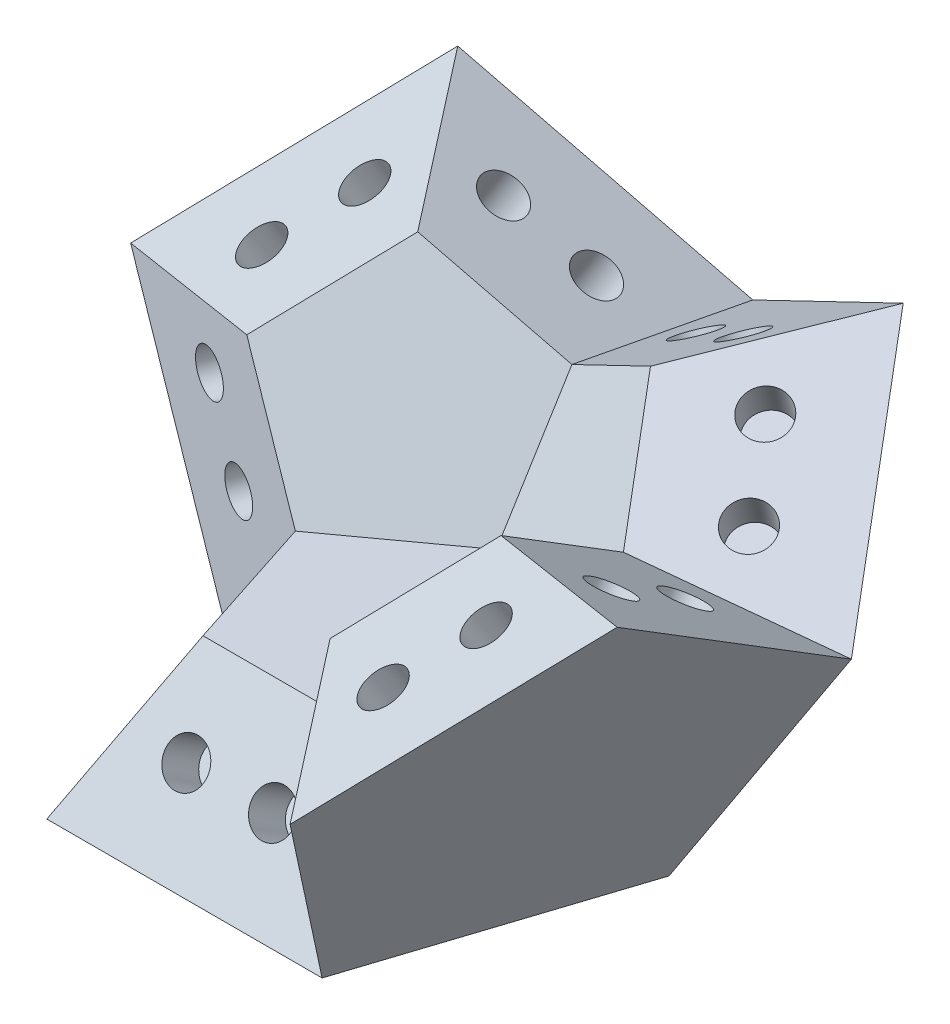
from build123d import *

# Parameters (mm, degrees)
BOSS_EXTRUDE1_DEPTH     = 6.752040791
BOSS_EXTRUDE1_TAPER     = 31.717474411
SKETCH3_R               = 1
CUT_EXTRUDE1_DEPTH      = 2
CIRPATTERN1_COUNT       = 5
MIRROR3_COPY_1_SKETCH_R = 1
MIRROR3_COPY_1_DEPTH    = 2
MIRROR3_COPY_2_SKETCH_R = 1
MIRROR3_COPY_2_DEPTH    = 2
MIRROR3_COPY_3_SKETCH_R = 1
MIRROR3_COPY_3_DEPTH    = 2
MIRROR3_COPY_4_SKETCH_R = 1
MIRROR3_COPY_4_DEPTH    = 2
MIRROR4_COPY_1_SKETCH_R = 1
MIRROR4_COPY_1_DEPTH    = 2
MIRROR4_COPY_2_SKETCH_R = 1
MIRROR4_COPY_2_DEPTH    = 2
MIRROR4_COPY_3_SKETCH_R = 1
MIRROR4_COPY_3_DEPTH    = 2
MIRROR4_COPY_4_SKETCH_R = 1
MIRROR4_COPY_4_DEPTH    = 2
MIRROR5_COPY_1_SKETCH_R = 1
MIRROR5_COPY_1_DEPTH    = 2
MIRROR5_COPY_2_SKETCH_R = 1
MIRROR5_COPY_2_DEPTH    = 2
MIRROR5_COPY_3_SKETCH_R = 1
MIRROR5_COPY_3_DEPTH    = 2
MIRROR5_COPY_4_SKETCH_R = 1
MIRROR5_COPY_4_DEPTH    = 2


with BuildPart() as part:
    # Sketch1 → Boss-Extrude1 (new body)
    with BuildSketch(Plane(origin=(0, 0, 0), x_dir=(1, 0, 0), z_dir=(0, 1, 0))):
        Polygon((0, 10.803265266), (-10.274515829, 3.338392562), (-6.35, -8.740025195), (6.35, -8.740025195), (10.274515829, 3.338392562), align=None)
    boss_extrude1 = extrude(amount=BOSS_EXTRUDE1_DEPTH, taper=BOSS_EXTRUDE1_TAPER)

    # Sketch3 → Cut-Extrude1 (cut)
    with BuildSketch(Plane(origin=(0, 3.908658092, 6.324341644), x_dir=(1, 0, 0), z_dir=(1.6266940928737823e-15, 0.5257311121191348, 0.8506508083520392))):
        with Locations((-2, -0.626153166)):
            Circle(SKETCH3_R)
        with Locations((2, -0.626153166)):
            Circle(SKETCH3_R)
    cut_extrude1 = extrude(amount=-CUT_EXTRUDE1_DEPTH, mode=Mode.SUBTRACT)

    # CirPattern1: Cut-Extrude1 ×5 about axis
    cirpattern1_axis = Axis((0, 14.848740719, 0), (0, -1, 0))
    for i in range(1, CIRPATTERN1_COUNT):
        add(cut_extrude1.rotate(cirpattern1_axis, i * 360 / CIRPATTERN1_COUNT), mode=Mode.SUBTRACT)

    # Mirror3: Boss-Extrude1, Cut-Extrude1 across plane
    add(boss_extrude1.mirror(Plane(origin=(10.274515829, 0, -3.338392562), x_dir=(0.4742680099309791, 0.49867489660708614, 0.7255296012224591), z_dir=(0.4999999999999987, 0.5257311121191346, -0.688190960235587))))
    add(cut_extrude1.mirror(Plane(origin=(10.274515829, 0, -3.338392562), x_dir=(0.4742680099309791, 0.49867489660708614, 0.7255296012224591), z_dir=(0.4999999999999987, 0.5257311121191346, -0.688190960235587))), mode=Mode.SUBTRACT)

    # Mirror3 copy 1 sketch → Mirror3 copy 1 (cut)
    with BuildSketch(Plane(origin=(3.717354749, 14.141657828, -11.440841512), x_dir=(0.8090169943749475, 0.5257311121191339, 0.26286555605956596), z_dir=(-0.5000000000000014, 0.8506508083520399, -0.16245984811644945))):
        with Locations((-2, 0.626153166)):
            Circle(MIRROR3_COPY_1_SKETCH_R)
        with Locations((2, 0.626153166)):
            Circle(MIRROR3_COPY_1_SKETCH_R)
    extrude(amount=-MIRROR3_COPY_1_DEPTH, mode=Mode.SUBTRACT)

    # Mirror3 copy 2 sketch → Mirror3 copy 2 (cut)
    with BuildSketch(Plane(origin=(0, 7.817316184, -10.232999736), x_dir=(-1.2043746199203667e-15, 0.8506508083520407, -0.5257311121191327), z_dir=(-1, 0, 0))):
        with Locations((-2, 0.626153166)):
            Circle(MIRROR3_COPY_2_SKETCH_R)
        with Locations((2, 0.626153166)):
            Circle(MIRROR3_COPY_2_SKETCH_R)
    extrude(amount=-MIRROR3_COPY_2_DEPTH, mode=Mode.SUBTRACT)

    # Mirror3 copy 3 sketch → Mirror3 copy 3 (cut)
    with BuildSketch(Plane(origin=(3.717354749, 3.908658092, -5.116499868), x_dir=(-0.8090169943749478, 0, -0.5877852522924727), z_dir=(-0.4999999999999993, -0.5257311121191345, 0.6881909602355869))):
        with Locations((-2, 0.626153166)):
            Circle(MIRROR3_COPY_3_SKETCH_R)
        with Locations((2, 0.626153166)):
            Circle(MIRROR3_COPY_3_SKETCH_R)
    extrude(amount=-MIRROR3_COPY_3_DEPTH, mode=Mode.SUBTRACT)

    # Mirror3 copy 4 sketch → Mirror3 copy 4 (cut)
    with BuildSketch(Plane(origin=(9.73216108, 7.817316184, -3.162170822), x_dir=(-0.4999999999999984, -0.8506508083520413, 0.1624598481164517), z_dir=(0.3090169943749473, -1.1894596157351711e-15, 0.9510565162951536))):
        with Locations((-2, 0.626153166)):
            Circle(MIRROR3_COPY_4_SKETCH_R)
        with Locations((2, 0.626153166)):
            Circle(MIRROR3_COPY_4_SKETCH_R)
    extrude(amount=-MIRROR3_COPY_4_DEPTH, mode=Mode.SUBTRACT)

    # Mirror4: Boss-Extrude1, Cut-Extrude1 across plane
    add(boss_extrude1.mirror(Plane(origin=(6.35, 0, 8.740025195), x_dir=(-0.22041412184245382, -0.1432337790289861, 0.9648324722134385), z_dir=(0.8090169943749472, 0.5257311121191346, 0.26286555605956535))))
    add(cut_extrude1.mirror(Plane(origin=(6.35, 0, 8.740025195), x_dir=(-0.22041412184245382, -0.1432337790289861, 0.9648324722134385), z_dir=(0.8090169943749472, 0.5257311121191346, 0.26286555605956535))), mode=Mode.SUBTRACT)

    # Mirror4 copy 1 sketch → Mirror4 copy 1 (cut)
    with BuildSketch(Plane(origin=(9.73216108, 14.141657828, 7.070828914), x_dir=(-0.49999999999999695, -0.5257311121191344, 0.6881909602355882), z_dir=(-0.30901699437495, 0.8506508083520392, 0.4253254041760192))):
        with Locations((-2, 0.626153166)):
            Circle(MIRROR4_COPY_1_SKETCH_R)
        with Locations((2, 0.626153166)):
            Circle(MIRROR4_COPY_1_SKETCH_R)
    extrude(amount=-MIRROR4_COPY_1_DEPTH, mode=Mode.SUBTRACT)

    # Mirror4 copy 2 sketch → Mirror4 copy 2 (cut)
    with BuildSketch(Plane(origin=(12.029612663, 14.141657828, 0), x_dir=(0, 0.5257311121191339, 0.8506508083520398), z_dir=(-4.1633363423443354e-15, 0.8506508083520398, -0.5257311121191338))):
        with Locations((-2, 0.626153166)):
            Circle(MIRROR4_COPY_2_SKETCH_R)
        with Locations((2, 0.626153166)):
            Circle(MIRROR4_COPY_2_SKETCH_R)
    extrude(amount=-MIRROR4_COPY_2_DEPTH, mode=Mode.SUBTRACT)

    # Mirror4 copy 3 sketch → Mirror4 copy 3 (cut)
    with BuildSketch(Plane(origin=(9.73216108, 7.817316184, -3.162170822), x_dir=(0.4999999999999985, 0.8506508083520405, -0.1624598481164543), z_dir=(-0.3090169943749497, 0, -0.9510565162951529))):
        with Locations((-2, 0.626153166)):
            Circle(MIRROR4_COPY_3_SKETCH_R)
        with Locations((2, 0.626153166)):
            Circle(MIRROR4_COPY_3_SKETCH_R)
    extrude(amount=-MIRROR4_COPY_3_DEPTH, mode=Mode.SUBTRACT)

    # Mirror4 copy 4 sketch → Mirror4 copy 4 (cut)
    with BuildSketch(Plane(origin=(6.014806331, 3.908658092, 1.954329046), x_dir=(0.3090169943749467, 0, -0.9510565162951539), z_dir=(-0.8090169943749471, -0.5257311121191344, -0.2628655560595658))):
        with Locations((-2, 0.626153166)):
            Circle(MIRROR4_COPY_4_SKETCH_R)
        with Locations((2, 0.626153166)):
            Circle(MIRROR4_COPY_4_SKETCH_R)
    extrude(amount=-MIRROR4_COPY_4_DEPTH, mode=Mode.SUBTRACT)

    # Mirror5: Boss-Extrude1, Cut-Extrude1 across plane
    add(boss_extrude1.mirror(Plane(origin=(0, 0, -10.803265266), x_dir=(-0.4742680099309791, 0.49867489660708403, 0.7255296012224607), z_dir=(-0.5000000000000008, 0.5257311121191346, -0.6881909602355855))))
    add(cut_extrude1.mirror(Plane(origin=(0, 0, -10.803265266), x_dir=(-0.4742680099309791, 0.49867489660708403, 0.7255296012224607), z_dir=(-0.5000000000000008, 0.5257311121191346, -0.6881909602355855))), mode=Mode.SUBTRACT)

    # Mirror5 copy 1 sketch → Mirror5 copy 1 (cut)
    with BuildSketch(Plane(origin=(-9.73216108, 7.817316184, -3.162170822), x_dir=(-0.4999999999999997, 0.8506508083520404, -0.16245984811645123), z_dir=(-0.30901699437494484, 0, 0.9510565162951544))):
        with Locations((-2, 0.626153166)):
            Circle(MIRROR5_COPY_1_SKETCH_R)
        with Locations((2, 0.626153166)):
            Circle(MIRROR5_COPY_1_SKETCH_R)
    extrude(amount=-MIRROR5_COPY_1_DEPTH, mode=Mode.SUBTRACT)

    # Mirror5 copy 2 sketch → Mirror5 copy 2 (cut)
    with BuildSketch(Plane(origin=(-3.717354749, 3.908658092, -5.116499868), x_dir=(-0.8090169943749469, 0, 0.587785252292474), z_dir=(0.5000000000000007, -0.5257311121191344, 0.6881909602355858))):
        with Locations((-2, 0.626153166)):
            Circle(MIRROR5_COPY_2_SKETCH_R)
        with Locations((2, 0.626153166)):
            Circle(MIRROR5_COPY_2_SKETCH_R)
    extrude(amount=-MIRROR5_COPY_2_DEPTH, mode=Mode.SUBTRACT)

    # Mirror5 copy 3 sketch → Mirror5 copy 3 (cut)
    with BuildSketch(Plane(origin=(0, 7.817316184, -10.232999736), x_dir=(0, -0.8506508083520413, 0.5257311121191314), z_dir=(1, 0, 0))):
        with Locations((-2, 0.626153166)):
            Circle(MIRROR5_COPY_3_SKETCH_R)
        with Locations((2, 0.626153166)):
            Circle(MIRROR5_COPY_3_SKETCH_R)
    extrude(amount=-MIRROR5_COPY_3_DEPTH, mode=Mode.SUBTRACT)

    # Mirror5 copy 4 sketch → Mirror5 copy 4 (cut)
    with BuildSketch(Plane(origin=(-3.717354749, 14.141657828, -11.440841512), x_dir=(0.809016994374946, -0.5257311121191345, -0.2628655560595698), z_dir=(0.5000000000000017, 0.8506508083520392, -0.16245984811645123))):
        with Locations((-2, 0.626153166)):
            Circle(MIRROR5_COPY_4_SKETCH_R)
        with Locations((2, 0.626153166)):
            Circle(MIRROR5_COPY_4_SKETCH_R)
    extrude(amount=-MIRROR5_COPY_4_DEPTH, mode=Mode.SUBTRACT)


solid = part.part
